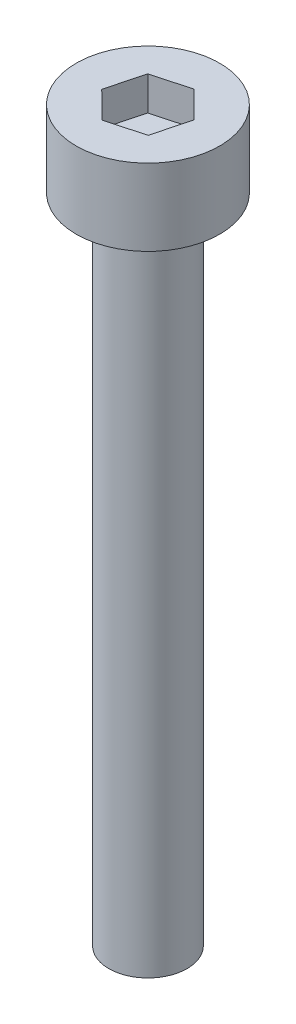
from build123d import *

# Parameters (mm, degrees)
SKETCH_1_R          = 1.5
EXTRUDE_1_DEPTH     = 25
SKETCH_2_R          = 2.75
EXTRUDE_2_DEPTH     = 2.93
CUT_EXTRUDE_1_DEPTH = 1.3


with BuildPart() as part:
    # 草图1 → 凸台-拉伸1 (new body)
    with BuildSketch(Plane(origin=(0, 0, 0), x_dir=(1, 0, 0), z_dir=(0, 1, 0))):
        Circle(SKETCH_1_R)
    extrude(amount=EXTRUDE_1_DEPTH)

    # 草图2 → 凸台-拉伸2 (add)
    with BuildSketch(Plane(origin=(0, 25, 0), x_dir=(1, 0, 0), z_dir=(0, 1, 0))):
        Circle(SKETCH_2_R)
    extrude(amount=EXTRUDE_2_DEPTH)

    # 草图3 → 切除-拉伸1 (cut)
    with BuildSketch(Plane(origin=(0, 27.93, 0), x_dir=(1, 0, 0), z_dir=(0, 1, 0))):
        Polygon((1.024005842, -1.017224346), (1.392945046, 0.378202899), (0.368939204, 1.395427245), (-1.024005842, 1.017224346), (-1.392945046, -0.378202899), (-0.368939204, -1.395427245), align=None)
    extrude(amount=-CUT_EXTRUDE_1_DEPTH, mode=Mode.SUBTRACT)


solid = part.part
